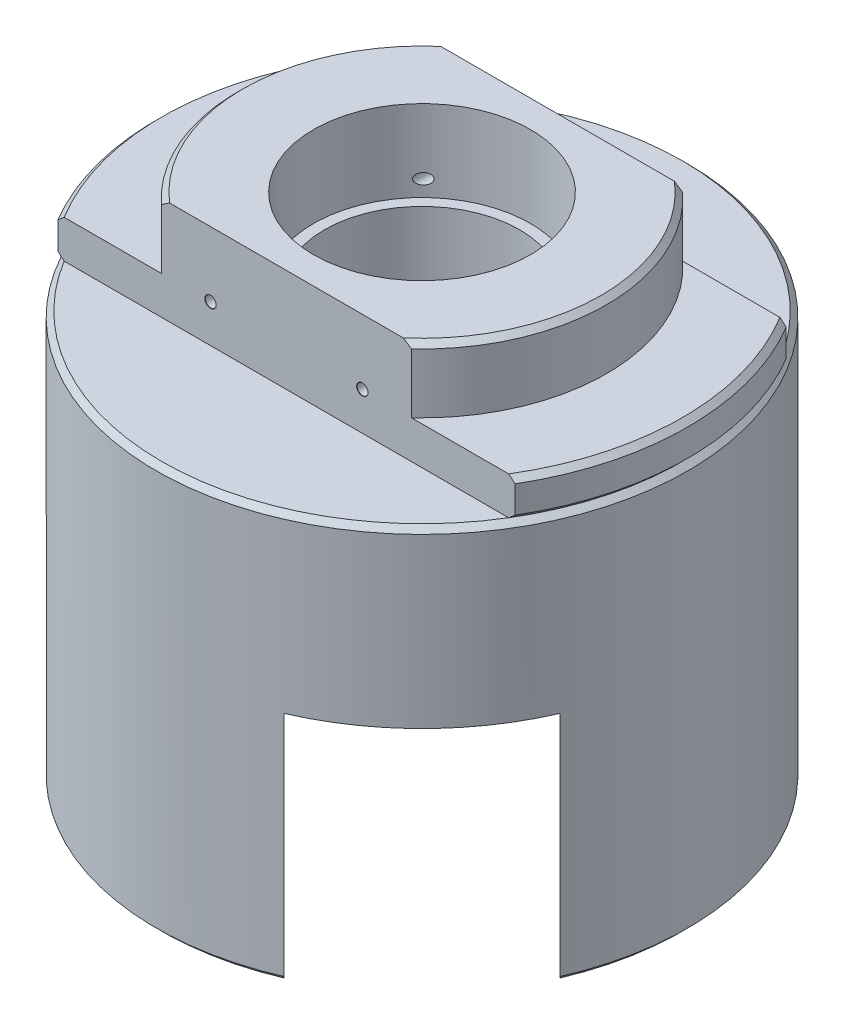
from build123d import *

# Parameters (mm, degrees)
SKETCH_1_R                     = 24.5
EXTRUDE_1_DEPTH                = 47
CUT_EXTRUDE_2_DEPTH            = 9.5
SKETCH_4_R                     = 10
CUT_EXTRUDE_4_DEPTH            = 7.5
CUT_EXTRUDE_START              = 3.5
SKETCH_5_OUTSIDE_W             = 67.746
SKETCH_5_OUTSIDE_H             = 67.746
SKETCH_5_OUTSIDE_R             = 17
CUT_EXTRUDE_5_DEPTH            = 7
SKETCH_6_R                     = 9
CUT_EXTRUDE_6_DEPTH            = 40.5
CUT_EXTRUDE_10_DEPTH           = 29.5
CUT_EXTRUDE_11_DEPTH           = 21.5
HOLE_WIZARD_2_561_D            = 1.778
HOLE_WIZARD_2_561_DEPTH        = 10.2733
HOLE_WIZARD_2_561_CSINK_D      = 2.54
HOLE_WIZARD_2_561_CSINK_ANGLE  = 110
HOLE_WIZARD_2_561_TIP          = 0.53416509
HOLE_WIZARD_1_0_1_1_AT_2_COUNT = 2
HOLE_WIZARD_1_0_1_1_AT_2_PITCH = 14
CHAMFER_1_SIZE                 = 0.5


with BuildPart() as part:
    # Эскиз1 → Бобышка-Вытянуть1 (new body)
    with BuildSketch(Plane(origin=(0, 0, 0), x_dir=(1, 0, 0), z_dir=(0, 1, 0))):
        Circle(SKETCH_1_R)
    extrude(amount=EXTRUDE_1_DEPTH)

    # Эскиз2 → Вырез-Вытянуть2 (cut)
    with BuildSketch(Plane(origin=(0, 47, 0), x_dir=(1, 0, 0), z_dir=(0, 1, 0))):
        with BuildLine():
            ThreePointArc((21.071307506, 12.5), (0, 24.5), (-21.071307506, 12.5))
            Line((-21.071307506, 12.5), (21.071307506, 12.5))
        make_face()
        with BuildLine():
            Line((21.071307506, -12.5), (-21.071307506, -12.5))
            ThreePointArc((-21.071307506, -12.5), (0, -24.5), (21.071307506, -12.5))
        make_face()
    extrude(amount=-CUT_EXTRUDE_2_DEPTH, mode=Mode.SUBTRACT)

    # Эскиз4 → Вырез-Вытянуть4 (cut)
    with BuildSketch(Plane(origin=(0, 47, 0), x_dir=(1, 0, 0), z_dir=(0, 1, 0))):
        Circle(SKETCH_4_R)
    extrude(amount=-CUT_EXTRUDE_4_DEPTH, mode=Mode.SUBTRACT)

    # Эскиз5 outside → Вырез-Вытянуть5 (cut, through all)
    with BuildSketch(Plane(origin=(0, 37.5, 0), x_dir=(1, 0, 0), z_dir=(0, 1, 0)).offset(CUT_EXTRUDE_START)):
        Rectangle(SKETCH_5_OUTSIDE_W, SKETCH_5_OUTSIDE_H)
        Circle(SKETCH_5_OUTSIDE_R, mode=Mode.SUBTRACT)
    extrude(amount=CUT_EXTRUDE_5_DEPTH, mode=Mode.SUBTRACT)

    # Эскиз6 → Вырез-Вытянуть6 (cut, through all)
    with BuildSketch(Plane(origin=(0, 39.5, 0), x_dir=(1, 0, 0), z_dir=(0, 1, 0))):
        Circle(SKETCH_6_R)
    extrude(amount=-CUT_EXTRUDE_6_DEPTH, mode=Mode.SUBTRACT)

    # Эскиз7 → Вырез-Повернуть1 (revolve, cut)
    with BuildSketch(Plane.XY):
        Polygon((0, 32), (12, 32), (12, 7), (20, 7), (20, 0), (0, 0), align=None)
    revolve(axis=Axis((0, 0, 0), (0, 1, 0)), mode=Mode.SUBTRACT)

    # Эскиз13 → Вырез-Вытянуть10 (cut)
    with BuildSketch(Plane.XZ):
        with BuildLine():
            Line((2.828427125, 9.899494937), (7.071067812, 5.656854249))
            ThreePointArc((7.071067812, 5.656854249), (9.414213562, 0), (7.071067812, -5.656854249))
            Line((7.071067812, -5.656854249), (-2.828427125, -15.556349186))
            ThreePointArc((-2.828427125, -15.556349186), (-8.485281374, -17.899494937), (-14.142135624, -15.556349186))
            Line((-14.142135624, -15.556349186), (-18.384776311, -11.313708499))
            ThreePointArc((-18.384776311, -11.313708499), (-20.727922061, -5.656854249), (-18.384776311, 0))
            Line((-18.384776311, 0), (-8.485281374, 9.899494937))
            ThreePointArc((-8.485281374, 9.899494937), (-2.828427125, 12.242640687), (2.828427125, 9.899494937))
        make_face()
    extrude(amount=-CUT_EXTRUDE_10_DEPTH, mode=Mode.SUBTRACT)

    # Эскиз14 → Вырез-Вытянуть11 (cut)
    with BuildSketch(Plane.XZ):
        with BuildLine():
            Line((9.748922014, 22.476844075), (6.26536991, 18.993291971))
            ThreePointArc((6.26536991, 18.993291971), (14.142135624, 14.142135624), (18.993291971, 6.26536991))
            Line((18.993291971, 6.26536991), (22.476844075, 9.748922014))
            ThreePointArc((22.476844075, 9.748922014), (17.324116139, 17.324116139), (9.748922014, 22.476844075))
        make_face()
        with BuildLine():
            Line((6.26536991, 18.993291971), (-6.363961031, 6.363961031))
            Line((-6.363961031, 6.363961031), (6.363961031, -6.363961031))
            Line((6.363961031, -6.363961031), (18.993291971, 6.26536991))
            ThreePointArc((18.993291971, 6.26536991), (14.142135624, 14.142135624), (6.26536991, 18.993291971))
        make_face()
    extrude(amount=-CUT_EXTRUDE_11_DEPTH, mode=Mode.SUBTRACT)

    # Отверстие обработанное метчиком #2-561
    with Locations(Plane.XZ.offset(-7)):
        with Locations((0, -16.970562748), (16.970562748, 0), (-16.263455967, 5.656854249)):
            CounterSinkHole(HOLE_WIZARD_2_561_D / 2, HOLE_WIZARD_2_561_CSINK_D / 2, depth=HOLE_WIZARD_2_561_DEPTH, counter_sink_angle=HOLE_WIZARD_2_561_CSINK_ANGLE)
            with Locations((0, 0, -(HOLE_WIZARD_2_561_DEPTH + HOLE_WIZARD_2_561_TIP / 2))):  # 118° drill point
                Cone(0, HOLE_WIZARD_2_561_D / 2, HOLE_WIZARD_2_561_TIP, mode=Mode.SUBTRACT)

    # Эскиз23 → Диаметр отверстия Ø1.0 (1)1 (revolve, cut)
    with BuildSketch(Plane(origin=(-7, 41, 12.5), x_dir=(0, -1, 0), z_dir=(1, 0, 0))):
        Polygon((0, 0), (0, 25), (0.525, 25), (0.5, 24.975), (0.5, 0.025), (0.525, 0), align=None)
    hole_wizard_1_0_1_1 = revolve(axis=Axis((-7, 41, 18.85), (0, 0, -1)), mode=Mode.SUBTRACT)

    # Диаметр отверстия Ø1.0 (1)1 at 2: Диаметр отверстия Ø1.0 (1)1 ×2
    with Locations(*[(i * HOLE_WIZARD_1_0_1_1_AT_2_PITCH, 0, 0) for i in range(1, HOLE_WIZARD_1_0_1_1_AT_2_COUNT)]):
        add(hole_wizard_1_0_1_1, mode=Mode.SUBTRACT)

    # Эскиз24 → Вырез-Повернуть2 (revolve, cut)
    with BuildSketch(Plane(origin=(0, 0, 0), x_dir=(0, 0, -1), z_dir=(1, 0, 0))):
        Polygon((24.5, 37.000075506), (24.000075506, 37.5), (24.5, 37.999924494), align=None)
    revolve(axis=Axis((0, 0, 0), (0, 1, 0)), mode=Mode.SUBTRACT)

    # Фаска1
    chamfer_1_edges = [part.edges().sort_by_distance(p)[0] for p in [
        (-20.482902496, 0, -13.442496246),
        (-17, 47, 0),
        (17, 47, 0),
        (-24.5, 41, 0),
        (24.5, 41, 0),
    ]]
    chamfer(chamfer_1_edges, length=CHAMFER_1_SIZE)


solid = part.part
